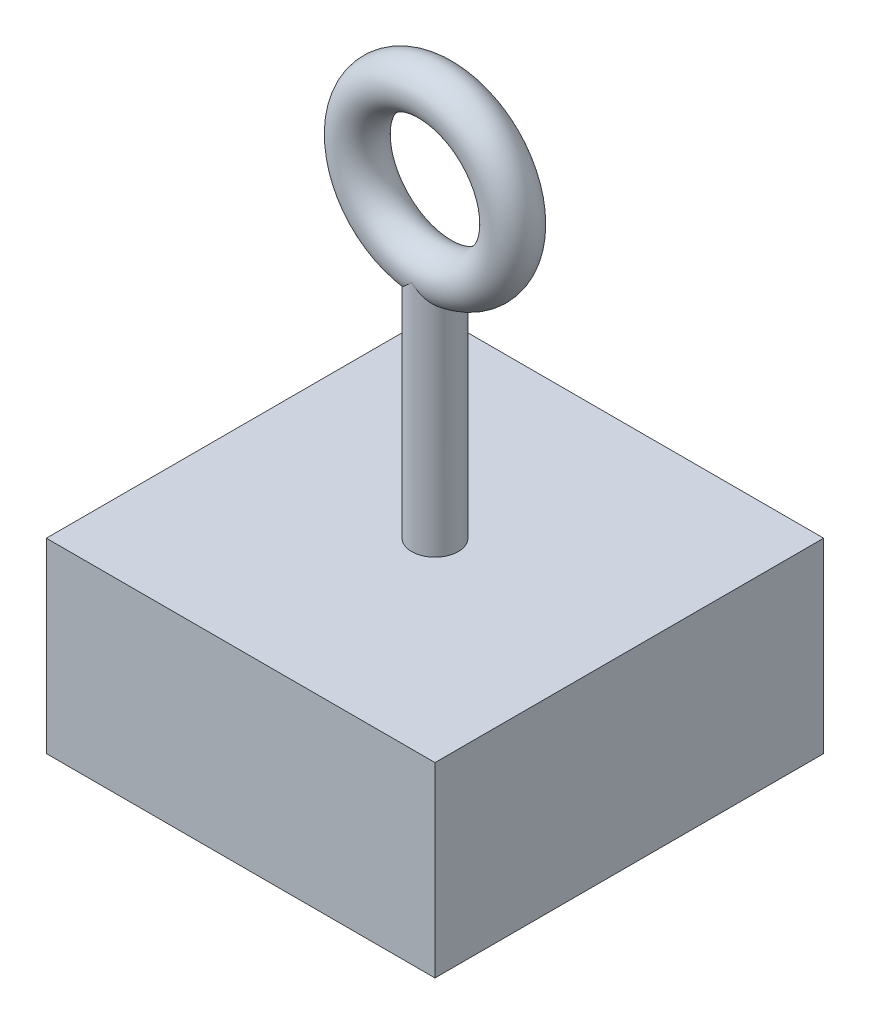
from build123d import *

# Parameters (mm, degrees)
SKETCH1_W           = 25
SKETCH1_H           = 25
BOSS_EXTRUDE1_DEPTH = 12
SKETCH2_R           = 1.5
BOSS_EXTRUDE2_DEPTH = 15
SKETCH3_R           = 1.5


with BuildPart() as part:
    # Sketch1 → Boss-Extrude1 (new body)
    with BuildSketch(Plane(origin=(0, 0, 0), x_dir=(1, 0, 0), z_dir=(0, 1, 0))):
        Rectangle(SKETCH1_W, SKETCH1_H)
    extrude(amount=BOSS_EXTRUDE1_DEPTH)

    # Sketch2 → Boss-Extrude2 (add)
    with BuildSketch(Plane(origin=(0, 12, 0), x_dir=(1, 0, 0), z_dir=(0, 1, 0))):
        Circle(SKETCH2_R)
    extrude(amount=BOSS_EXTRUDE2_DEPTH)

    # Sketch3 → Revolve1 (revolve)
    with BuildSketch(Plane(origin=(0, 31.999999906, 0), x_dir=(1, 0, 0), z_dir=(0, 1, 0))):
        with Locations((-5, 0)):
            Circle(SKETCH3_R)
    revolve(axis=Axis((0, 31.999999906, -13.75), (0, 0, 1)))


solid = part.part
